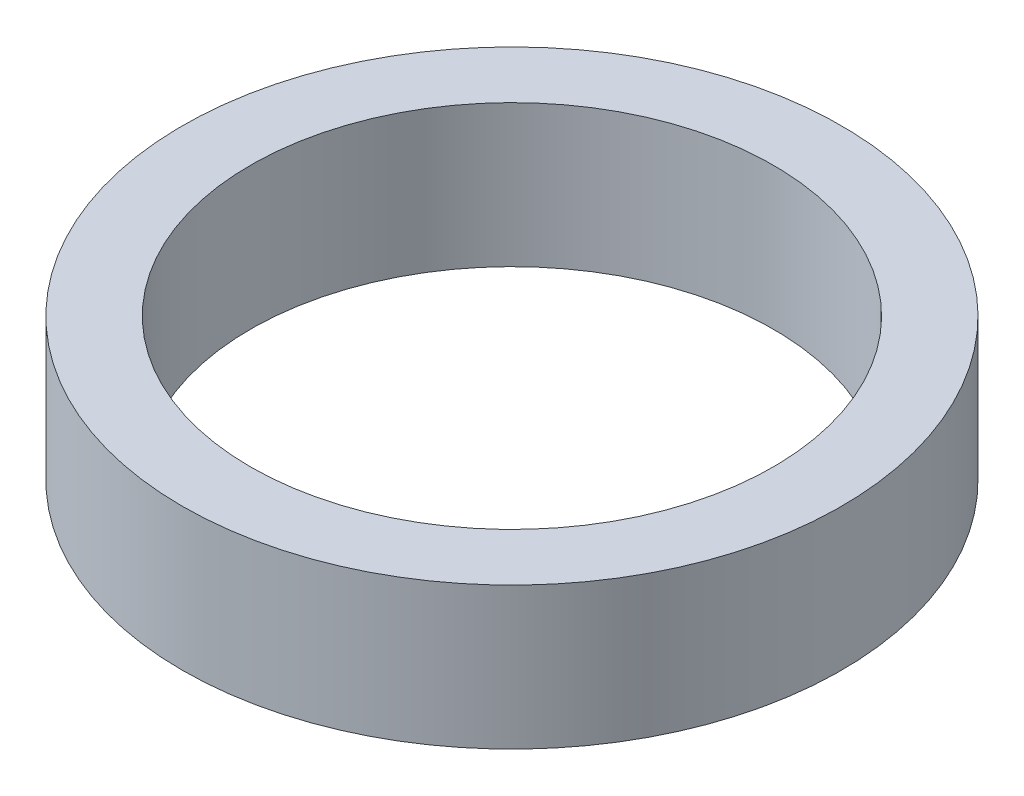
from build123d import *

# Parameters (mm, degrees)
SKETCH1_R           = 290
BOSS_EXTRUDE1_DEPTH = 125
SKETCH2_R           = 230
CUT_EXTRUDE1_DEPTH  = 126


with BuildPart() as part:
    # Sketch1 → Boss-Extrude1 (new body)
    with BuildSketch(Plane(origin=(0, 0, 0), x_dir=(1, 0, 0), z_dir=(0, 1, 0))):
        Circle(SKETCH1_R)
    extrude(amount=BOSS_EXTRUDE1_DEPTH)

    # Sketch2 → Cut-Extrude1 (cut, through all)
    with BuildSketch(Plane(origin=(0, 125, 0), x_dir=(1, 0, 0), z_dir=(0, 1, 0))):
        Circle(SKETCH2_R)
    extrude(amount=-CUT_EXTRUDE1_DEPTH, mode=Mode.SUBTRACT)


solid = part.part
